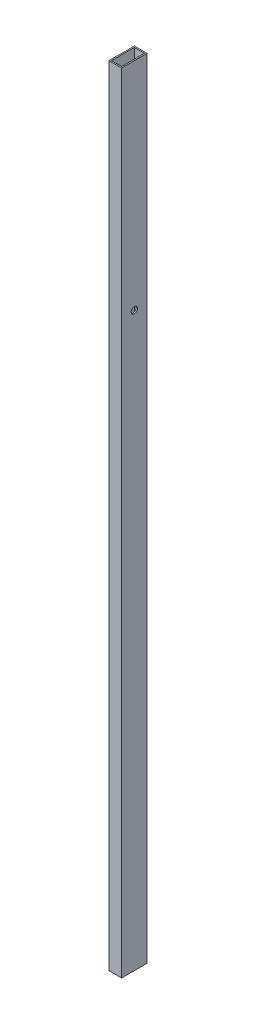
from build123d import *

# Parameters (mm, degrees)
SKETCH_1_W          = 20
SKETCH_1_H          = 40
SKETCH_1_W_2        = 16
SKETCH_1_H_2        = 36
EXTRUDE_1_DEPTH     = 1240
SKETCH_2_R          = 5
CUT_EXTRUDE_1_DEPTH = 21
SKETCH_3_R          = 5
CUT_EXTRUDE_2_DEPTH = 10


with BuildPart() as part:
    # Эскиз1 → Вытянуть-Тонкостенный1 (new body)
    with BuildSketch(Plane(origin=(0, 0, 0), x_dir=(1, 0, 0), z_dir=(0, 1, 0))):
        Rectangle(SKETCH_1_W, SKETCH_1_H)
        Rectangle(SKETCH_1_W_2, SKETCH_1_H_2, mode=Mode.SUBTRACT)
    extrude(amount=EXTRUDE_1_DEPTH)

    # Эскиз2 → Вырез-Вытянуть1 (cut, through all)
    with BuildSketch(Plane(origin=(10, 0, 0), x_dir=(0, 0, -1), z_dir=(1, 0, 0))):
        with Locations((0, 900)):
            Circle(SKETCH_2_R)
    extrude(amount=-CUT_EXTRUDE_1_DEPTH, mode=Mode.SUBTRACT)

    # Эскиз3 → Вырез-Вытянуть2 (cut)
    with BuildSketch(Plane.ZY.offset(10)):
        with Locations((0, 720)):
            Circle(SKETCH_3_R)
        with Locations((0, 580)):
            Circle(SKETCH_3_R)
        with Locations((0, 440)):
            Circle(SKETCH_3_R)
    extrude(amount=-CUT_EXTRUDE_2_DEPTH, mode=Mode.SUBTRACT)


solid = part.part
